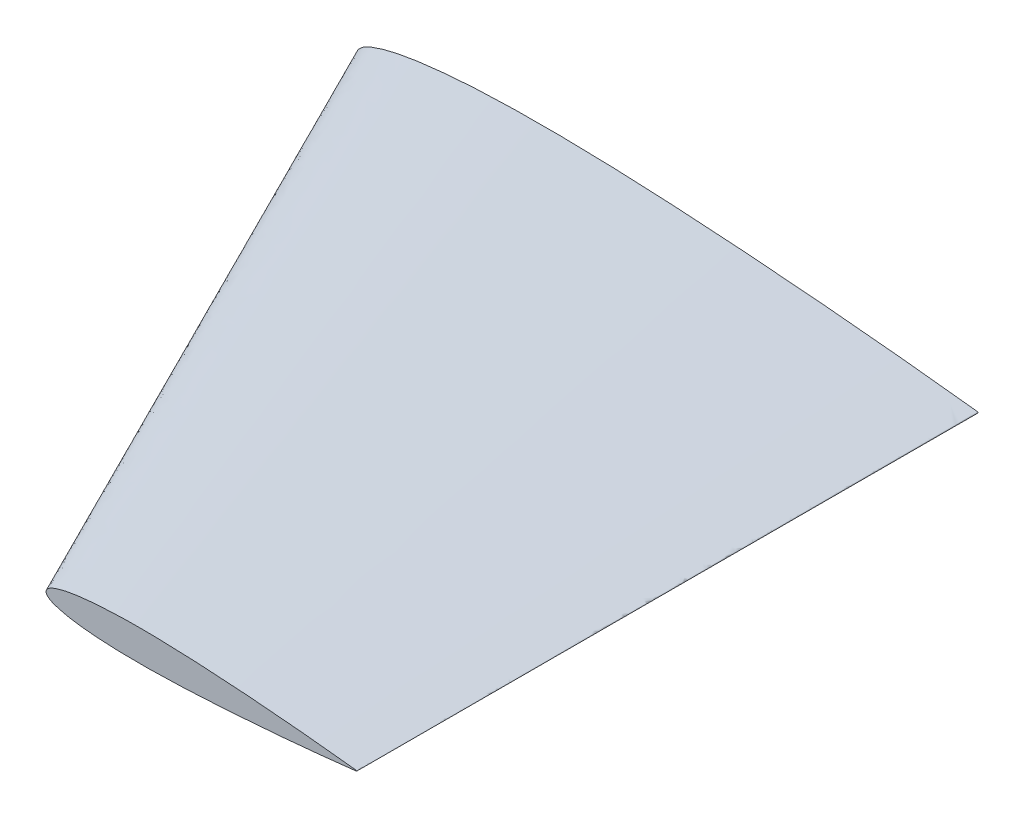
from build123d import *


with BuildPart() as part:
    # Sketch7 for Loft6 → Loft6 section 0
    with BuildSketch(Plane.XY):
        with BuildLine():
            # circular arc as an exact rational Bezier (weights 1, cos(half-angle), 1)
            Bezier((200, 0.21), (201.838050231, 0), (200, -0.21), weights=[1, 0.113513038, 1])
            add(Edge.make_bspline(
                [(200, 0.21), (196.667124956, 0.590785981), (190.00354754, 1.352109711), (176.67365877, 2.775076547), (160.009949216, 4.404350076), (140.009625952, 6.148237112), (120.009854239, 7.657957699), (100.009190596, 8.875959196), (80.008154036, 9.755322031), (63.334225978, 10.06037124), (49.997402977, 9.940233729), (39.992939342, 9.608299058), (29.979945852, 8.983969519), (21.645028536, 8.086010773), (14.971099842, 7.038024179), (9.960226154, 5.990688443), (5.693788879, 4.688655222), (2.157571208, 3.198387819), (-1.278013379, 0), (2.157571208, -3.198387819), (5.693788879, -4.688655222), (9.960226154, -5.990688443), (14.971099842, -7.038024179), (21.645028536, -8.086010773), (29.979945852, -8.983969519), (39.992939342, -9.608299058), (49.997402977, -9.940233729), (63.334225978, -10.06037124), (80.008154036, -9.755322031), (100.009190596, -8.875959196), (120.009854239, -7.657957699), (140.009625952, -6.148237112), (160.009949216, -4.404350076), (176.67365877, -2.775076547), (190.00354754, -1.352109711), (196.667124956, -0.590785981), (200, -0.21)],
                knots=[0, 0, 0, 0, 0.024822337, 0.049628492, 0.099195532, 0.148712593, 0.198181861, 0.247602781, 0.296978033, 0.346315468, 0.370982061, 0.395661674, 0.420379085, 0.445195931, 0.457685472, 0.470302569, 0.483221568, 0.490061482, 0.5, 0.509938518, 0.516778432, 0.529697431, 0.542314528, 0.554804069, 0.579620915, 0.604338326, 0.629017939, 0.653684532, 0.703021967, 0.752397219, 0.801818139, 0.851287407, 0.900804468, 0.950371508, 0.975177663, 1, 1, 1, 1], degree=3))
        make_face()
    # Sketch8 for Loft6 → Loft6 section 1
    with BuildSketch(Plane.XY.offset(200)):
        with BuildLine():
            Bezier((199.988003592, -0.105), (200.907028705, 0), (199.988003592, 0.105), weights=[1, 0.113513039, 1])
            add(Edge.make_bspline(
                [(199.988003592, 0.105), (198.32156607, 0.29539299), (194.989777362, 0.676054856), (188.324832977, 1.387538274), (179.9929782, 2.202175038), (169.992816568, 3.074118556), (159.992930712, 3.82897885), (149.99259889, 4.437979598), (139.99208061, 4.877661016), (131.655116581, 5.03018562), (124.986705081, 4.970116865), (119.984473263, 4.804149529), (114.977976518, 4.491984759), (110.81051786, 4.043005386), (107.473553513, 3.519012089), (104.968116669, 2.995344221), (102.834898032, 2.344327611), (101.066789196, 1.59919391), (99.348996903, 0), (101.066789196, -1.59919391), (102.834898032, -2.344327611), (104.968116669, -2.995344221), (107.473553513, -3.519012089), (110.81051786, -4.043005386), (114.977976518, -4.491984759), (119.984473263, -4.804149529), (124.986705081, -4.970116865), (131.655116581, -5.03018562), (139.99208061, -4.877661016), (149.99259889, -4.437979598), (159.992930712, -3.82897885), (169.992816568, -3.074118556), (179.9929782, -2.202175038), (188.324832977, -1.387538274), (194.989777362, -0.676054856), (198.32156607, -0.29539299), (199.988003592, -0.105)],
                knots=[0, 0, 0, 0, 0.024822337, 0.049628492, 0.099195532, 0.148712593, 0.198181861, 0.247602781, 0.296978033, 0.346315468, 0.370982061, 0.395661674, 0.420379085, 0.445195931, 0.457685472, 0.470302569, 0.483221568, 0.490061482, 0.5, 0.509938518, 0.516778432, 0.529697431, 0.542314528, 0.554804069, 0.579620915, 0.604338326, 0.629017939, 0.653684532, 0.703021967, 0.752397219, 0.801818139, 0.851287407, 0.900804468, 0.950371508, 0.975177663, 1, 1, 1, 1], degree=3))
        make_face()
    loft()


solid = part.part
